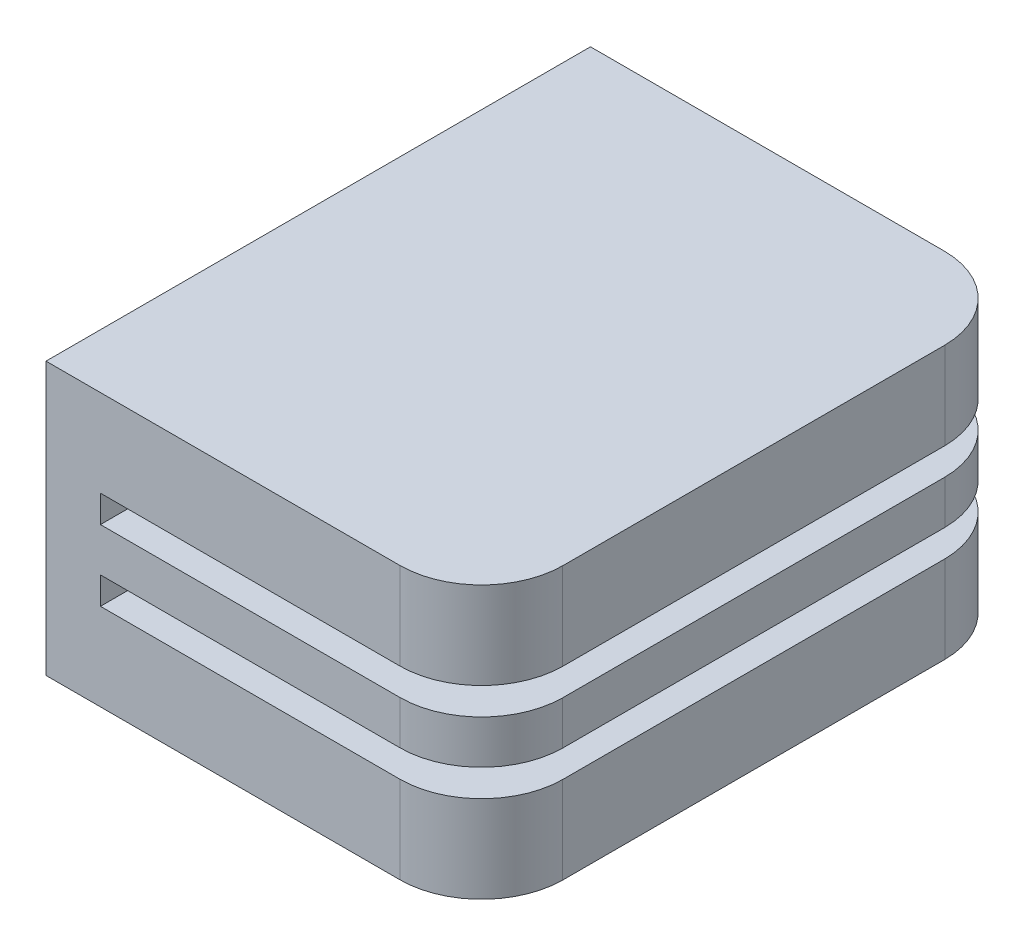
from build123d import *

# Parameters (mm, degrees)
SKETCH1_W           = 8
SKETCH1_H           = 10
BOSS_EXTRUDE1_DEPTH = 5
CUT_EXTRUDE1_REACH  = 12
SKETCH2_W           = 7
SKETCH2_H           = 0.5
CUT_EXTRUDE3_DEPTH  = 5


with BuildPart() as part:
    # Sketch1 → Boss-Extrude1 (new body)
    with BuildSketch(Plane(origin=(0, 0, 0), x_dir=(1, 0, 0), z_dir=(0, 1, 0))):
        Rectangle(SKETCH1_W, SKETCH1_H)
    extrude(amount=-BOSS_EXTRUDE1_DEPTH)

    # Sketch2 → Cut-Extrude1 (cut, up to next)
    with BuildSketch(Plane(origin=(0, 0, -5), x_dir=(-1, 0, 0), z_dir=(0, 0, -1)), mode=Mode.PRIVATE) as cut_extrude1_sk1:
        with Locations((-0.5, -1.85)):
            Rectangle(SKETCH2_W, SKETCH2_H)
    cut_extrude1_tool1 = extrude(cut_extrude1_sk1.sketch, amount=-CUT_EXTRUDE1_REACH, mode=Mode.PRIVATE) & part.part
    add(cut_extrude1_tool1.solids().sort_by_distance((0.5, -1.85, -5))[0], mode=Mode.SUBTRACT)
    # Sketch2 → Cut-Extrude1 (cut, up to next)
    with BuildSketch(Plane(origin=(0, 0, -5), x_dir=(-1, 0, 0), z_dir=(0, 0, -1)), mode=Mode.PRIVATE) as cut_extrude1_sk2:
        with Locations((-0.5, -3.15)):
            Rectangle(SKETCH2_W, SKETCH2_H)
    cut_extrude1_tool2 = extrude(cut_extrude1_sk2.sketch, amount=-CUT_EXTRUDE1_REACH, mode=Mode.PRIVATE) & part.part
    add(cut_extrude1_tool2.solids().sort_by_distance((0.5, -3.15, -5))[0], mode=Mode.SUBTRACT)

    # Sketch3 → Cut-Extrude3 (cut)
    with BuildSketch(Plane(origin=(0, 0, 0), x_dir=(1, 0, 0), z_dir=(0, 1, 0))):
        with BuildLine():
            Line((2.500033416, 5), (4, 5))
            Line((4, 5), (4, 3.510012302))
            ThreePointArc((4, 3.510012302), (3.557147777, 4.564194168), (2.500033416, 5))
        make_face()
        with BuildLine():
            Line((4, -3.510012302), (4, -5))
            Line((4, -5), (2.500033416, -5))
            ThreePointArc((2.500033416, -5), (3.557147777, -4.564194168), (4, -3.510012302))
        make_face()
    extrude(amount=-CUT_EXTRUDE3_DEPTH, mode=Mode.SUBTRACT)


solid = part.part
